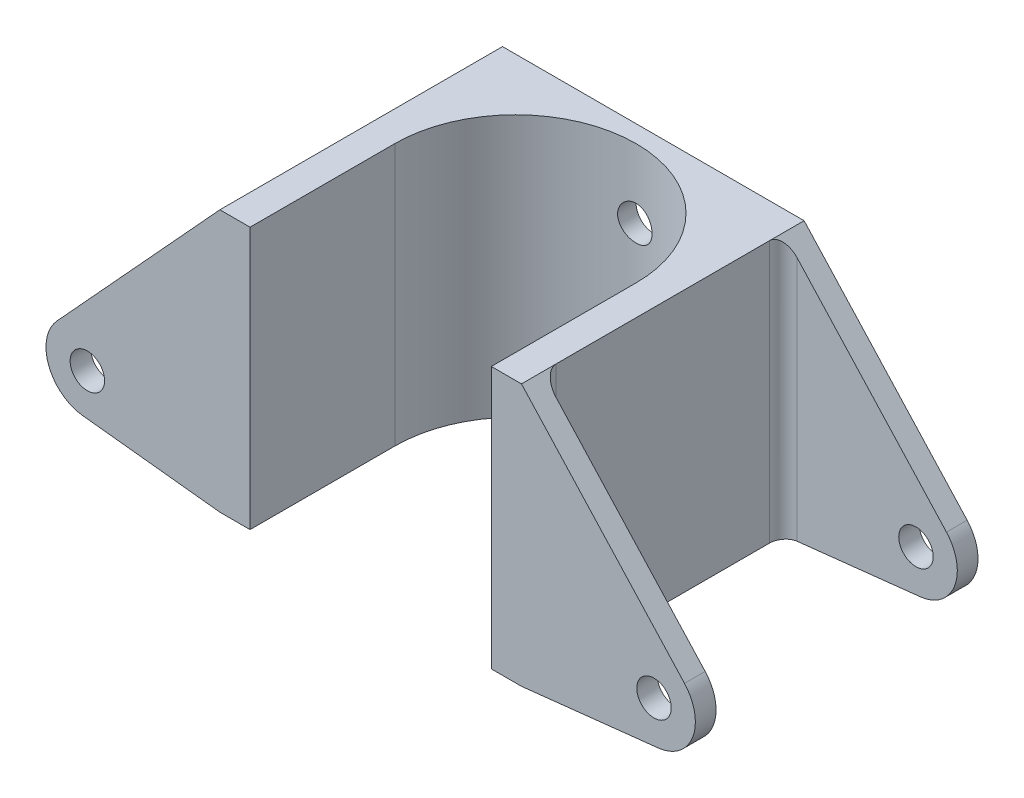
from build123d import *

# Parameters (mm, degrees)
BOSS_EXTRUDE1_DEPTH     = 41
SKETCH3_W               = 25.226628976
SKETCH3_H               = 35
CUT_EXTRUDE2_DEPTH      = 39
CUT_EXTRUDE2_DEPTH_BACK = 1
CUT_EXTRUDE3_DEPTH      = 39
SKETCH5_R               = 2.5
CUT_EXTRUDE4_DEPTH      = 42
SKETCH6_R               = 2.5
CUT_EXTRUDE5_DEPTH      = 42.0000001
FILLET1_R               = 2


with BuildPart() as part:
    # Sketch1 → Boss-Extrude1 (new body)
    with BuildSketch(Plane.XY):
        with BuildLine():
            Line((-21.875, 0), (-41.755779843, 2.180502889))
            ThreePointArc((-41.755779843, 2.180502889), (-46.717396797, 6.03211956), (-45.524663567, 12.198964882))
            Line((-45.524663567, 12.198964882), (-21.875, 38))
            Line((-21.875, 38), (21.875, 38))
            Line((21.875, 38), (45.524663567, 12.198964882))
            ThreePointArc((45.524663567, 12.198964882), (46.717396797, 6.03211956), (41.755779843, 2.180502889))
            Line((41.755779843, 2.180502889), (21.875, 0))
            Line((21.875, 0), (-21.875, 0))
        make_face()
    extrude(amount=BOSS_EXTRUDE1_DEPTH)

    # Sketch3 → Cut-Extrude2 (cut, two sides)
    with BuildSketch(Plane(origin=(0, 0, 0), x_dir=(1, 0, 0), z_dir=(0, 1, 0))) as cut_extrude2_sk:
        with Locations((34.488314488, -20.5)):
            Rectangle(SKETCH3_W, SKETCH3_H)
        with Locations((-34.488314488, -20.5)):
            Rectangle(SKETCH3_W, SKETCH3_H)
    extrude(amount=CUT_EXTRUDE2_DEPTH, mode=Mode.SUBTRACT)
    extrude(cut_extrude2_sk.sketch, amount=-CUT_EXTRUDE2_DEPTH_BACK, mode=Mode.SUBTRACT)

    # Sketch4 → Cut-Extrude3 (cut, through all)
    with BuildSketch(Plane.XZ):
        with BuildLine():
            Line((-17.5, 20), (-17.5, 41))
            Line((-17.5, 41), (17.5, 41))
            Line((17.5, 41), (17.5, 20))
            ThreePointArc((17.5, 20), (0, 2.5), (-17.5, 20))
        make_face()
    extrude(amount=-CUT_EXTRUDE3_DEPTH, mode=Mode.SUBTRACT)

    # Sketch5 → Cut-Extrude4 (cut, through all)
    with BuildSketch(Plane(origin=(0, 0, 0), x_dir=(-1, 0, 0), z_dir=(0, 0, -1))):
        with Locations((0, 28)):
            Circle(SKETCH5_R)
        with Locations((0, 10)):
            Circle(SKETCH5_R)
    extrude(amount=-CUT_EXTRUDE4_DEPTH, mode=Mode.SUBTRACT)

    # Sketch6 → Cut-Extrude5 (cut, through all)
    with BuildSketch(Plane.XY.offset(41)):
        with Locations((-41.101628976, 8.144736842)):
            Circle(SKETCH6_R)
    cut_extrude5 = extrude(amount=-CUT_EXTRUDE5_DEPTH, mode=Mode.SUBTRACT)

    # Mirror1: Cut-Extrude5 across plane
    add(cut_extrude5.mirror(Plane(origin=(0, 0, 0), x_dir=(0, 0, 1), z_dir=(1, 0, 0))), mode=Mode.SUBTRACT)

    # Fillet1
    fillet1_edges = [part.edges().sort_by_distance(p)[0] for p in [
        (21.875, 19, 3),
        (21.875, 19, 38),
        (-21.875, 19, 38),
        (-21.875, 19, 3),
    ]]
    fillet(fillet1_edges, radius=FILLET1_R)


solid = part.part
